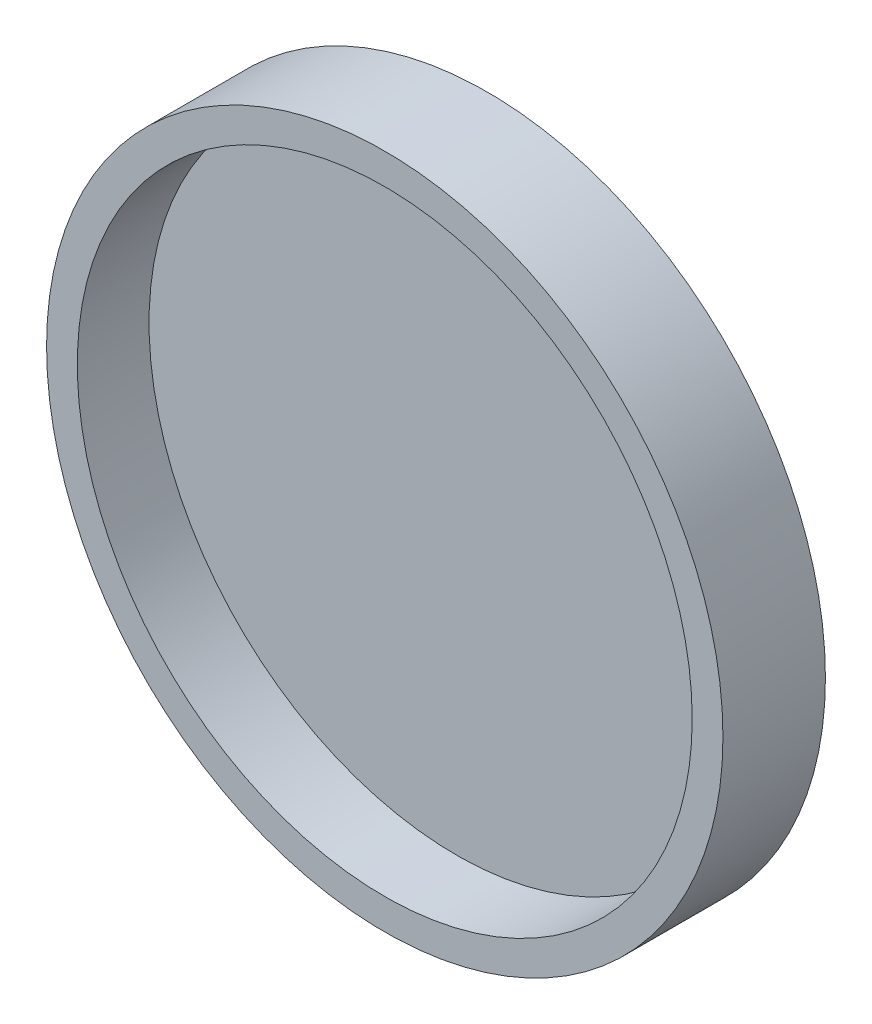
from build123d import *

# Parameters (mm, degrees)
SKETCH1_R           = 33
BOSS_EXTRUDE1_DEPTH = 10
SHELL1_T            = -3


with BuildPart() as part:
    # Sketch1 → Boss-Extrude1 (new body)
    with BuildSketch(Plane.XY):
        with Locations((-34.840786691, 9.705898633)):
            Circle(SKETCH1_R)
    extrude(amount=BOSS_EXTRUDE1_DEPTH)

    # Shell1
    shell1_openings = [part.faces().sort_by_distance(p)[0] for p in [
        (-1.840786691, 9.705898633, 10),
    ]]
    offset(amount=SHELL1_T, openings=shell1_openings, kind=Kind.INTERSECTION)


solid = part.part
